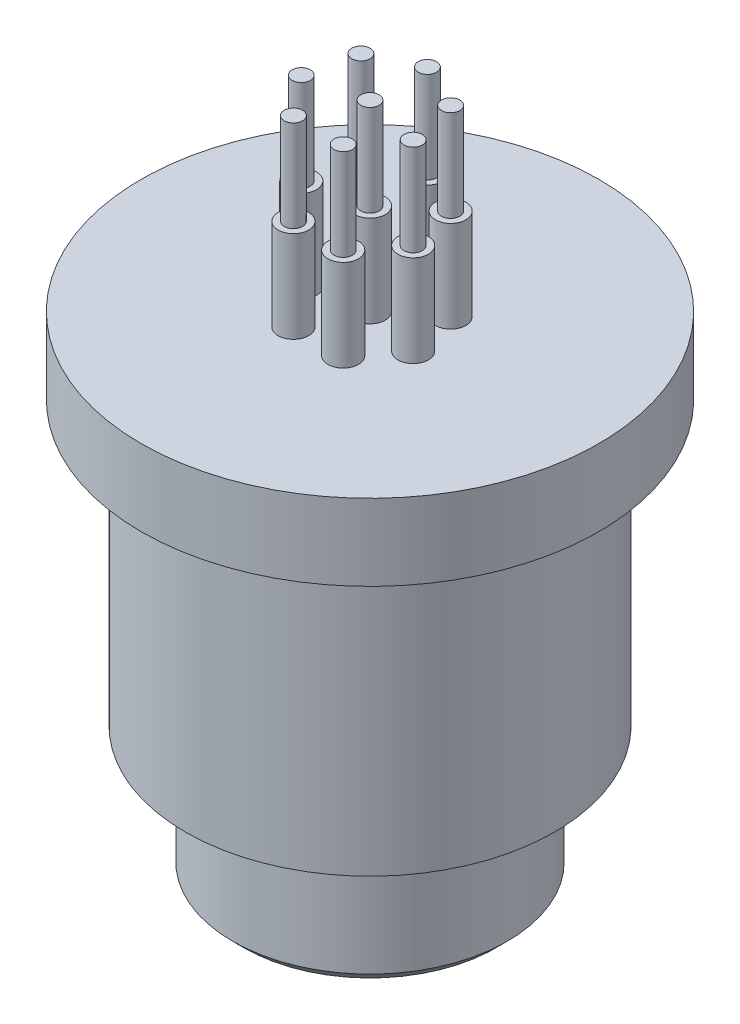
from build123d import *

# Parameters (mm, degrees)
SKETCH1_R            = 4.5
SKETCH1_R_2          = 3.5
BOSS_EXTRUDE1_DEPTH  = 4.25
SKETCH2_R            = 4.25
BOSS_EXTRUDE2_DEPTH  = 1.3
SKETCH3_R            = 6.05
BOSS_EXTRUDE3_DEPTH  = 9.25
SKETCH6_R            = 7.5
BOSS_EXTRUDE5_DEPTH  = 2.5
SKETCH10_R           = 0.5
BOSS_EXTRUDE7_DEPTH  = 3
SKETCH11_R           = 0.3
BOSS_EXTRUDE8_DEPTH  = 3
SKETCH11_3_R         = 0.3
BOSS_EXTRUDE9_DEPTH  = 3
CHAMFER1_SIZE        = 0.375
CHAMFER2_SIZE        = 0.375
BOSS_EXTRUDE12_REACH = 24.375
BOSS_EXTRUDE12_START = -0.375
SKETCH19_R           = 3.125
SKETCH20_R           = 0.4
CUT_EXTRUDE3_DEPTH   = 3.875


with BuildPart() as part:
    # Sketch1 → Boss-Extrude1 (new body)
    with BuildSketch(Plane(origin=(0, 0, 0), x_dir=(1, 0, 0), z_dir=(0, 1, 0))):
        Circle(SKETCH1_R)
        Circle(SKETCH1_R_2, mode=Mode.SUBTRACT)
    extrude(amount=BOSS_EXTRUDE1_DEPTH)

    # Sketch2 → Boss-Extrude2 (add)
    with BuildSketch(Plane(origin=(0, 4.25, 0), x_dir=(1, 0, 0), z_dir=(0, 1, 0))):
        Circle(SKETCH2_R)
    extrude(amount=-BOSS_EXTRUDE2_DEPTH)

    # Sketch3 → Boss-Extrude3 (add)
    with BuildSketch(Plane(origin=(0, 4.25, 0), x_dir=(1, 0, 0), z_dir=(0, 1, 0))):
        Circle(SKETCH3_R)
    extrude(amount=BOSS_EXTRUDE3_DEPTH)

    # Sketch6 → Boss-Extrude5 (add)
    with BuildSketch(Plane(origin=(0, 13.5, 0), x_dir=(1, 0, 0), z_dir=(0, 1, 0))):
        Circle(SKETCH6_R)
    extrude(amount=BOSS_EXTRUDE5_DEPTH)

    # Sketch10 → Boss-Extrude7 (add)
    with BuildSketch(Plane(origin=(0, 16, 0), x_dir=(1, 0, 0), z_dir=(0, 1, 0))):
        Circle(SKETCH10_R)
        with Locations((0, 1.88)):
            Circle(SKETCH10_R)
        with Locations((1.469843187, 1.172160827)):
            Circle(SKETCH10_R)
        with Locations((1.832864475, -0.418339356)):
            Circle(SKETCH10_R)
        with Locations((0.81570143, -1.693821472)):
            Circle(SKETCH10_R)
        with Locations((-0.81570143, -1.693821472)):
            Circle(SKETCH10_R)
        with Locations((-1.832864475, -0.418339356)):
            Circle(SKETCH10_R)
        with Locations((-1.469843187, 1.172160827)):
            Circle(SKETCH10_R)
    extrude(amount=BOSS_EXTRUDE7_DEPTH)

    # Sketch11 → Boss-Extrude8 (add)
    with BuildSketch(Plane(origin=(0, 19, 0), x_dir=(1, 0, 0), z_dir=(0, 1, 0))):
        with Locations((-0.81570143, -1.693821472)):
            Circle(SKETCH11_R)
    extrude(amount=BOSS_EXTRUDE8_DEPTH)

    # Sketch11_3 → Boss-Extrude9 (add)
    with BuildSketch(Plane(origin=(0, 19, 0), x_dir=(1, 0, 0), z_dir=(0, 1, 0))):
        Circle(SKETCH11_3_R)
        with Locations((0, 1.88)):
            Circle(SKETCH11_3_R)
        with Locations((1.469843187, 1.172160827)):
            Circle(SKETCH11_3_R)
        with Locations((1.832864475, -0.418339356)):
            Circle(SKETCH11_3_R)
        with Locations((0.81570143, -1.693821472)):
            Circle(SKETCH11_3_R)
        with Locations((-0.81570143, -1.693821472)):
            Circle(SKETCH11_3_R)
        with Locations((-1.832864475, -0.418339356)):
            Circle(SKETCH11_3_R)
        with Locations((-1.469843187, 1.172160827)):
            Circle(SKETCH11_3_R)
    extrude(amount=BOSS_EXTRUDE9_DEPTH)

    # Chamfer1
    chamfer1_edges = [part.edges().sort_by_distance(p)[0] for p in [
        (-4.5, 0, 0),
    ]]
    chamfer(chamfer1_edges, length=CHAMFER1_SIZE)

    # Chamfer2
    chamfer2_edges = [part.edges().sort_by_distance(p)[0] for p in [
        (-3.5, 2.95, 0),
        (-3.5, 0, 0),
    ]]
    chamfer(chamfer2_edges, length=CHAMFER2_SIZE)

    # Sketch19 → Boss-Extrude12 (add, up to next)
    with BuildSketch(Plane.XZ.offset(BOSS_EXTRUDE12_START), mode=Mode.PRIVATE) as boss_extrude12_sk1:
        Circle(SKETCH19_R)
    boss_extrude12_tool1 = extrude(boss_extrude12_sk1.sketch, amount=-BOSS_EXTRUDE12_REACH, mode=Mode.PRIVATE) - part.part
    add(boss_extrude12_tool1.solids().sort_by_distance((0, 0.375, 0))[0])

    # Sketch20 → Cut-Extrude3 (cut)
    with BuildSketch(Plane.XZ.offset(-0.375)):
        Circle(SKETCH20_R)
        with Locations((0, 1.88)):
            Circle(SKETCH20_R)
        with Locations((1.469843187, 1.172160827)):
            Circle(SKETCH20_R)
        with Locations((1.832864475, -0.418339356)):
            Circle(SKETCH20_R)
        with Locations((0.81570143, -1.693821472)):
            Circle(SKETCH20_R)
        with Locations((-0.81570143, -1.693821472)):
            Circle(SKETCH20_R)
        with Locations((-1.832864475, -0.418339356)):
            Circle(SKETCH20_R)
        with Locations((-1.469843187, 1.172160827)):
            Circle(SKETCH20_R)
    extrude(amount=-CUT_EXTRUDE3_DEPTH, mode=Mode.SUBTRACT)


solid = part.part
